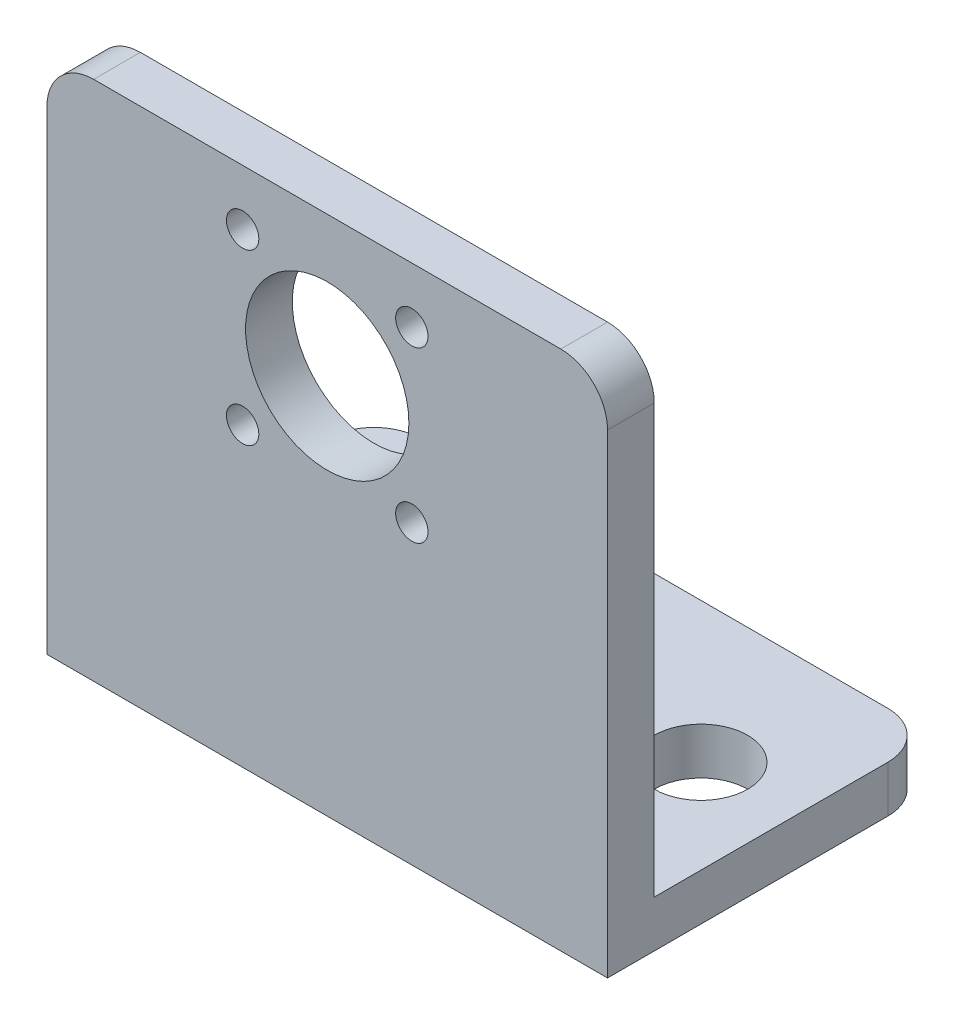
from build123d import *

# Parameters (mm, degrees)
SKETCH1_W                   = 38.1
SKETCH1_H                   = 35.433
SKETCH1_R                   = 5.55
BOSS_EXTRUDE1_DEPTH         = 3.175
SKETCH3_W                   = 38.1
SKETCH3_H                   = 3.175
BOSS_EXTRUDE2_DEPTH         = 19.05
FILLET1_R                   = 3.175
M2_CLEARANCE_HOLE1_D        = 2.2
F_1_4_0_25_DIAMETER_HOLE1_D = 6.35


with BuildPart() as part:
    # Sketch1 → Boss-Extrude1 (new body)
    with BuildSketch(Plane.XY):
        with Locations((0, -8.1915)):
            Rectangle(SKETCH1_W, SKETCH1_H)
        Circle(SKETCH1_R, mode=Mode.SUBTRACT)
    extrude(amount=BOSS_EXTRUDE1_DEPTH)

    # Sketch3 → Boss-Extrude2 (add)
    with BuildSketch(Plane(origin=(0, 0, 0), x_dir=(-1, 0, 0), z_dir=(0, 0, -1))):
        with Locations((0, -24.3205)):
            Rectangle(SKETCH3_W, SKETCH3_H)
    extrude(amount=BOSS_EXTRUDE2_DEPTH)

    # Fillet1
    fillet1_edges = [part.edges().sort_by_distance(p)[0] for p in [
        (-19.05, -24.3205, -19.05),
        (19.05, -24.3205, -19.05),
        (-19.05, 9.525, 1.5875),
        (19.05, 9.525, 1.5875),
    ]]
    fillet(fillet1_edges, radius=FILLET1_R)

    # M2 Clearance Hole1 (through all)
    with Locations(Plane(origin=(0, -25.908, 3.175), x_dir=(1, 0, 0), z_dir=(0, 0, 1))):
        with Locations((5.75, 31.658), (-5.75, 31.658), (5.75, 20.158), (-5.75, 20.158)):
            Hole(M2_CLEARANCE_HOLE1_D / 2)

    # 1/4 (0.25) Diameter Hole1 (through all)
    with Locations(Plane(origin=(0, -22.733, 0), x_dir=(1, 0, 0), z_dir=(0, 1, 0))):
        with Locations((-12.7, 9.525), (12.7, 9.525)):
            Hole(F_1_4_0_25_DIAMETER_HOLE1_D / 2)


solid = part.part
